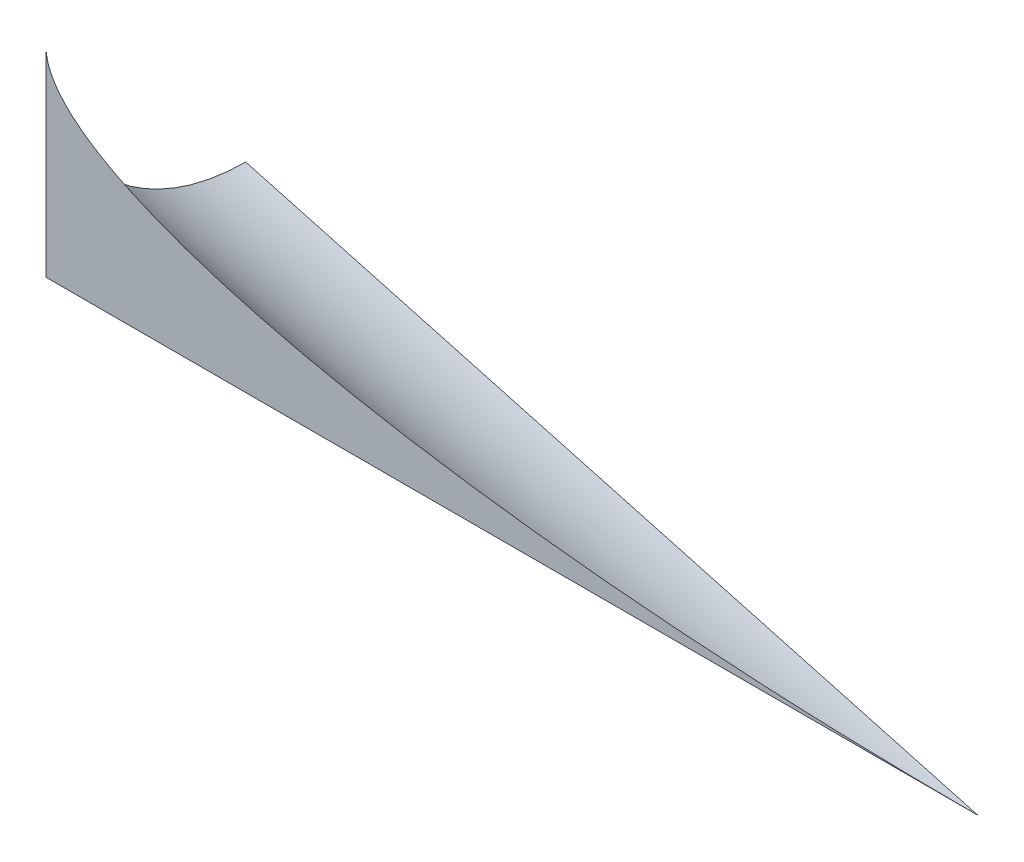
from build123d import *

# Parameters (mm, degrees)
ESQUISSE1_W        = 15
ESQUISSE1_H        = 15
BOSS_EXTRU_1_DEPTH = 70


with BuildPart() as part:
    # Esquisse1 → Boss.-Extru.1 (new body)
    with BuildSketch(Plane(origin=(0, 0, 0), x_dir=(0, 0, -1), z_dir=(1, 0, 0))):
        with Locations((7.5, 7.5)):
            Rectangle(ESQUISSE1_W, ESQUISSE1_H)
    extrude(amount=BOSS_EXTRU_1_DEPTH)

    # Enlèvement de matière-Balayage2: sweep along a curve in space
    with BuildLine() as enl_vement_de_mati_re_balayage2_path:
        Line((0, 0, -15), (70, 0, 0))
    # Esquisse2 → Enlèvement de matière-Balayage2 (sweep, cut)
    with BuildSketch(Plane.ZY):
        with BuildLine():
            ThreePointArc((-15, 0), (-4.393398282, 4.393398282), (0, 15))
            Line((0, 15), (-15, 15))
            Line((-15, 15), (-15, 0))
        make_face()
    sweep(path=enl_vement_de_mati_re_balayage2_path.line, mode=Mode.SUBTRACT)


with BuildPart() as enl_vement_de_mati_re_balayage2_kept_pie:
    # of the separate pieces the step leaves, the one the design keeps (enl_vement_de_mati_re_balayage2_pieces_k)
    add(part.part.solids().sort_by_distance((0, 0, 0))[0])


solid = enl_vement_de_mati_re_balayage2_kept_pie.part
